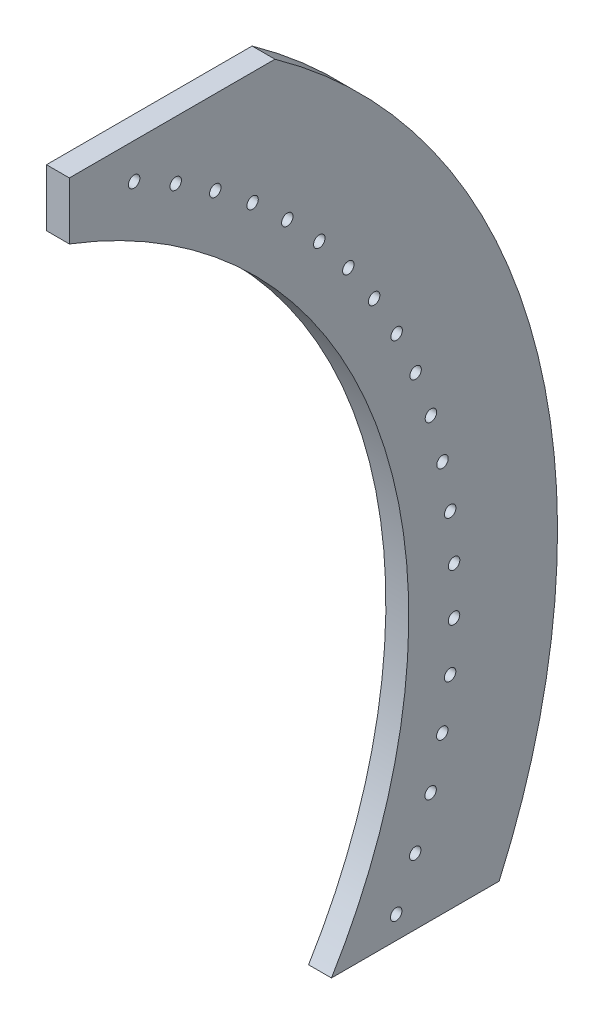
from build123d import *

# Parameters (mm, degrees)
BOSS_EXTRUDE1_DEPTH         = 12.7
SKETCH2_W                   = 852.307145123
SKETCH2_H                   = 152.4
CUT_EXTRUDE1_DEPTH          = 12.7
CUT_EXTRUDE2_DEPTH          = 12.7
F_1_4_0_25_DIAMETER_HOLE1_D = 6.35
CUT_EXTRUDE3_DEPTH          = 13.7


with BuildPart() as part:
    # Sketch1 → Boss-Extrude1 (new body)
    with BuildSketch(Plane(origin=(0, 0, 0), x_dir=(0, 0, -1), z_dir=(1, 0, 0))):
        with BuildLine():
            Line((0, 609.6), (323.85, 609.6))
            Line((323.85, 609.6), (323.85, 0))
            Line((323.85, 0), (0, 0))
            Line((0, 0), (0, 31.75))
            ThreePointArc((0, 31.75), (188.340145046, 304.8), (0, 577.85))
            Line((0, 577.85), (0, 609.6))
        make_face()
    extrude(amount=BOSS_EXTRUDE1_DEPTH)

    # Sketch2 → Cut-Extrude1 (cut)
    with BuildSketch(Plane(origin=(12.7, 0, 0), x_dir=(0, 0, -1), z_dir=(1, 0, 0))):
        with Locations((192.653341095, 76.2)):
            Rectangle(SKETCH2_W, SKETCH2_H)
    extrude(amount=-CUT_EXTRUDE1_DEPTH, mode=Mode.SUBTRACT)

    # Sketch3 → Cut-Extrude2 (cut)
    with BuildSketch(Plane(origin=(12.7, 0, 0), x_dir=(0, 0, -1), z_dir=(1, 0, 0))):
        with BuildLine():
            Line((270.760801555, 152.4), (323.85, 152.4))
            Line((323.85, 152.4), (323.85, 609.6))
            Line((323.85, 609.6), (161.925, 609.6))
            ThreePointArc((161.925, 609.6), (289.589524386, 398.436253262), (270.760801555, 152.4))
        make_face()
    extrude(amount=-CUT_EXTRUDE2_DEPTH, mode=Mode.SUBTRACT)

    # 1/4 (0.25) Diameter Hole1 (through all)
    with Locations(Plane(origin=(12.7, 0, 0), x_dir=(0, 0, -1), z_dir=(1, 0, 0))):
        with Locations((181.354437919, 165.1), (191.91696262, 189.121698017), (200.459714845, 213.933596133), (206.924338933, 239.366203925), (211.266674948, 265.245790893), (213.457060331, 291.395573216), (213.480532529, 317.636921367), (211.336931202, 343.790580328), (207.040899322, 369.677894089), (200.621783143, 395.122026048), (192.123431737, 419.949166985), (181.603897461, 443.989722351), (169.1350394, 467.079470776), (154.8020325, 489.060685868), (138.70278573, 509.783213636), (120.94727327, 529.105498206), (101.656783275, 546.89554878), (80.96308935, 563.031841274), (59.00755041, 577.404148448), (35.940145046, 589.914292872)):
            Hole(F_1_4_0_25_DIAMETER_HOLE1_D / 2)

    # Sketch6 → Cut-Extrude3 (cut, through all)
    with BuildSketch(Plane(origin=(12.7, 0, 0), x_dir=(0, 0, -1), z_dir=(1, 0, 0))):
        with BuildLine():
            Line((161.925, 609.6), (114.092348386, 609.6))
            ThreePointArc((114.092348386, 609.6), (257.747151872, 403.163135962), (238.492774693, 152.4))
            Line((238.492774693, 152.4), (270.760801555, 152.4))
            ThreePointArc((270.760801555, 152.4), (289.589524386, 398.436253262), (161.925, 609.6))
        make_face()
    extrude(amount=-CUT_EXTRUDE3_DEPTH, mode=Mode.SUBTRACT)


solid = part.part
